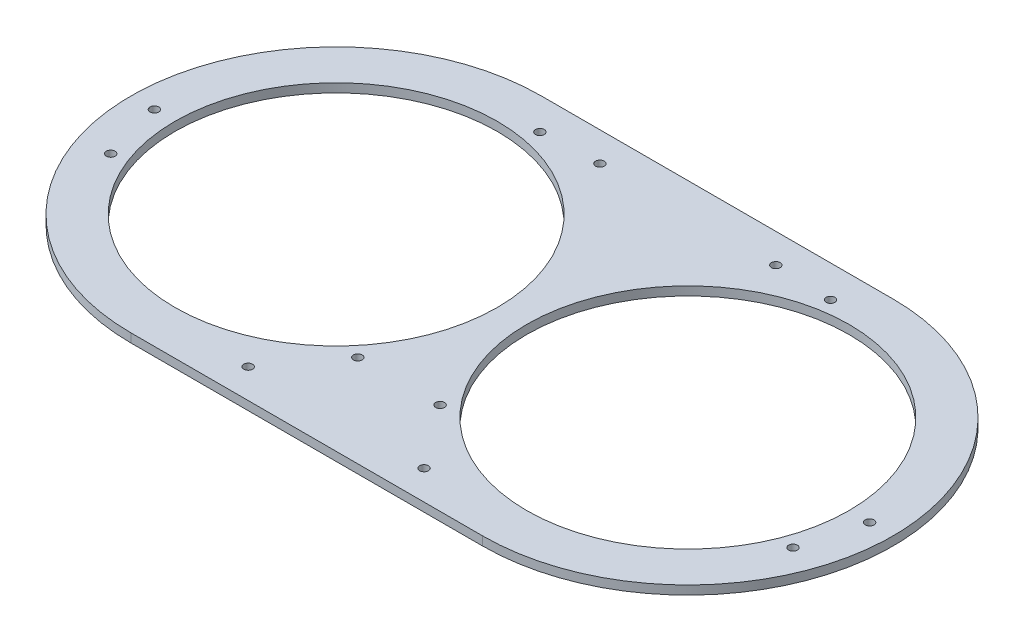
from build123d import *

# Parameters (mm, degrees)
SKETCH_1_R      = 55
SKETCH_1_R_2    = 1.5
EXTRUDE_2_DEPTH = 3


with BuildPart() as part:
    # 草图1 → 凸台-拉伸2 (new body)
    with BuildSketch(Plane(origin=(0, 0, 0), x_dir=(1, 0, 0), z_dir=(0, 1, 0))):
        with BuildLine():
            Line((-60, 70), (60, 70))
            ThreePointArc((60, 70), (130, 0), (60, -70))
            Line((60, -70), (-60, -70))
            ThreePointArc((-60, -70), (-130, 0), (-60, 70))
        make_face()
        with Locations((-60, 0)):
            Circle(SKETCH_1_R, mode=Mode.SUBTRACT)
        with Locations((60, 0)):
            Circle(SKETCH_1_R, mode=Mode.SUBTRACT)
        with Locations((-122, 0)):
            Circle(SKETCH_1_R_2, mode=Mode.SUBTRACT)
        with Locations((122, 0)):
            Circle(SKETCH_1_R_2, mode=Mode.SUBTRACT)
        with Locations((-30, 60)):
            Circle(SKETCH_1_R_2, mode=Mode.SUBTRACT)
        with Locations((30, 60)):
            Circle(SKETCH_1_R_2, mode=Mode.SUBTRACT)
        with Locations((30, -60)):
            Circle(SKETCH_1_R_2, mode=Mode.SUBTRACT)
        with Locations((-30, -60)):
            Circle(SKETCH_1_R_2, mode=Mode.SUBTRACT)
        with Locations((-49.58110934, 59.088465181)):
            Circle(SKETCH_1_R_2, mode=Mode.SUBTRACT)
        with Locations((-116.381557247, -20.5212086)):
            Circle(SKETCH_1_R_2, mode=Mode.SUBTRACT)
        with Locations((-14.037333413, -38.567256581)):
            Circle(SKETCH_1_R_2, mode=Mode.SUBTRACT)
        with Locations((14.037333413, -38.567256581)):
            Circle(SKETCH_1_R_2, mode=Mode.SUBTRACT)
        with Locations((116.381557247, -20.5212086)):
            Circle(SKETCH_1_R_2, mode=Mode.SUBTRACT)
        with Locations((49.58110934, 59.088465181)):
            Circle(SKETCH_1_R_2, mode=Mode.SUBTRACT)
    extrude(amount=EXTRUDE_2_DEPTH)


solid = part.part
